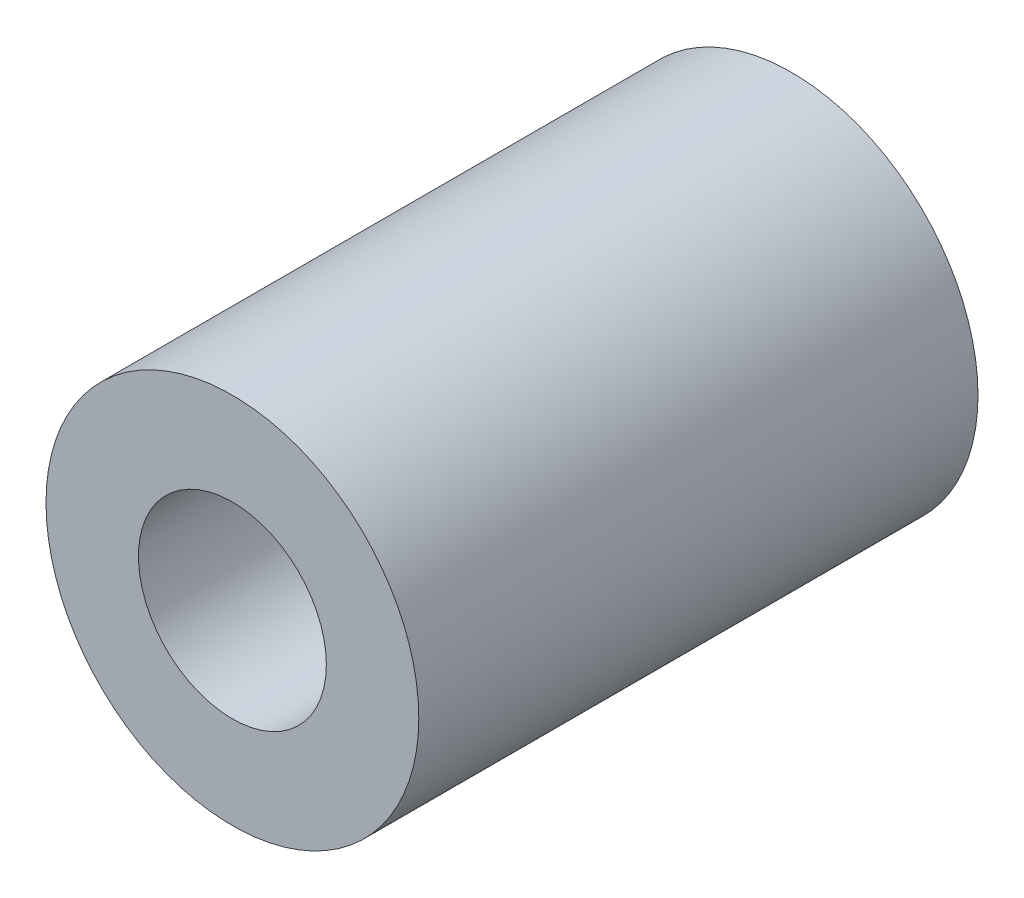
from build123d import *

# Parameters (mm, degrees)
SKETCH1_R           = 6.35
SKETCH1_R_2         = 3.2004
EXTRUDE1_DEPTH      = 9.525
EXTRUDE1_DEPTH_BACK = 9.525


with BuildPart() as part:
    # Sketch1 → Extrude1 (new body, two sides)
    with BuildSketch(Plane.XY) as extrude1_sk:
        Circle(SKETCH1_R)
        Circle(SKETCH1_R_2, mode=Mode.SUBTRACT)
    extrude(amount=EXTRUDE1_DEPTH)
    extrude(extrude1_sk.sketch, amount=-EXTRUDE1_DEPTH_BACK)


solid = part.part
